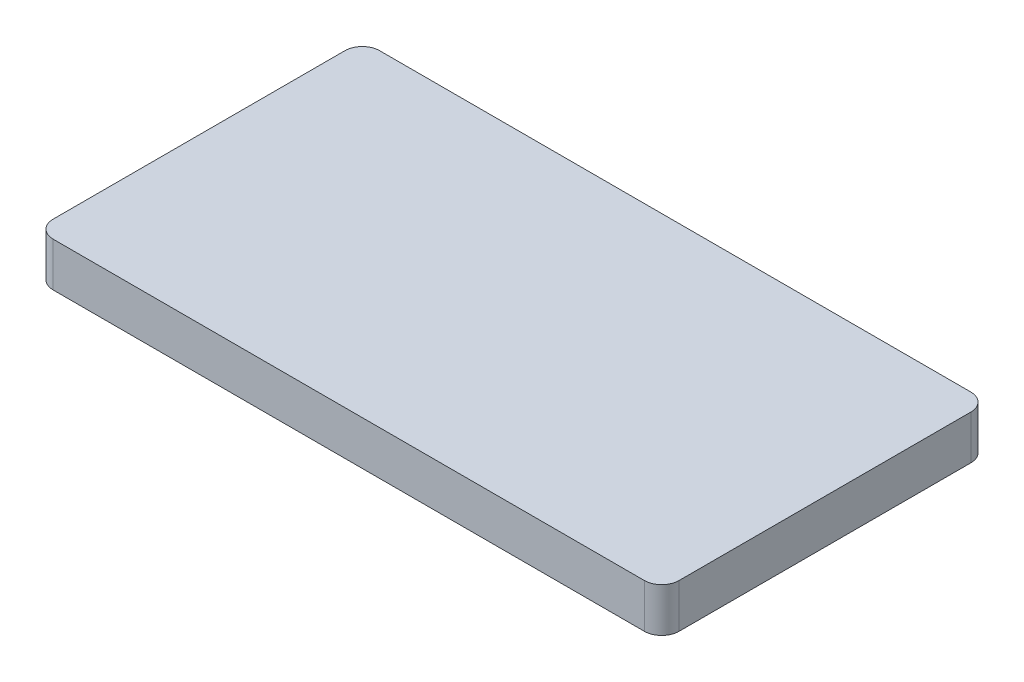
from build123d import *

# Parameters (mm, degrees)
SKETCH1_W           = 90.3
SKETCH1_H           = 47.1
BOSS_EXTRUDE1_DEPTH = 6.35
FILLET1_R           = 2.5


with BuildPart() as part:
    # Sketch1 → Boss-Extrude1 (new body)
    with BuildSketch(Plane(origin=(0, 0, 0), x_dir=(1, 0, 0), z_dir=(0, 1, 0))):
        Rectangle(SKETCH1_W, SKETCH1_H)
    extrude(amount=BOSS_EXTRUDE1_DEPTH)

    # Fillet1
    fillet1_edges = [part.edges().sort_by_distance(p)[0] for p in [
        (-45.15, 3.175, -23.55),
        (45.15, 3.175, -23.55),
        (45.15, 3.175, 23.55),
        (-45.15, 3.175, 23.55),
    ]]
    fillet(fillet1_edges, radius=FILLET1_R)


solid = part.part
